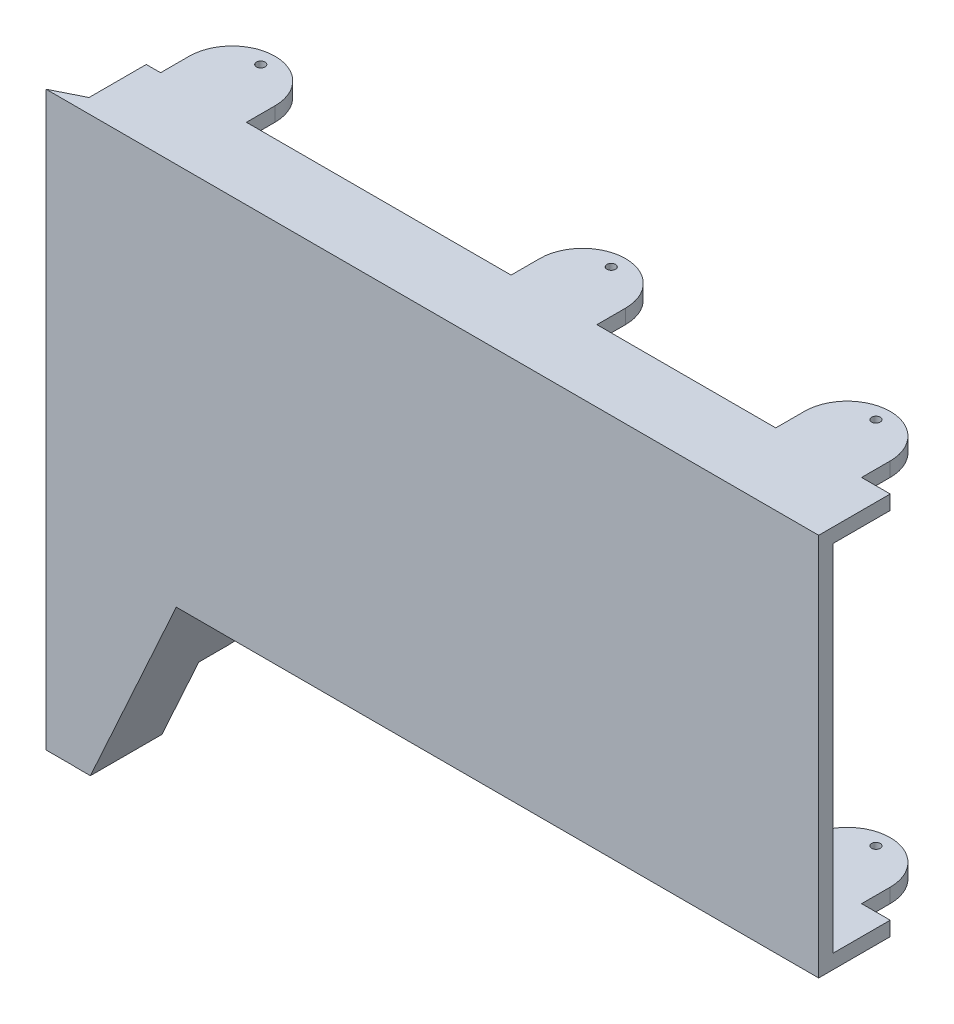
from build123d import *

# Parameters (mm, degrees)
SKETCH1_W                                  = 260
SKETCH1_H                                  = 134
BOSS_EXTRUDE1_DEPTH                        = 5
SKETCH2_W                                  = 260
SKETCH2_H                                  = 5
BOSS_EXTRUDE2_DEPTH                        = 20
SKETCH4_W                                  = 230
SKETCH4_H                                  = 5
BOSS_EXTRUDE3_DEPTH                        = 20
BOSS_EXTRUDE4_DEPTH                        = 5
SKETCH7_R                                  = 1.5
CUT_EXTRUDE1_DEPTH                         = 5
BOSS_EXTRUDE5_DEPTH                        = 5
BOSS_EXTRUDE9_DEPTH                        = 25
BOSS_EXTRUDE10_DEPTH                       = 200
BOSS_EXTRUDE11_DEPTH                       = 5
SKETCH14_R                                 = 1.5
CUT_EXTRUDE2_DEPTH                         = 5
BOSS_EXTRUDE12_DEPTH                       = 10
BOSS_EXTRUDE13_DEPTH                       = 5
SKETCH19_R                                 = 1.5
CUT_EXTRUDE4_DEPTH                         = 307.022874962
CUT_EXTRUDE4_DEPTH_BACK                    = 307.022874962
MIRROR4_AT_THE_SECOND_PLANE_COPY_1_DEPTH   = 5
MIRROR4_AT_THE_SECOND_PLANE_COPY_2_SKETC_R = 1.5
MIRROR4_AT_THE_SECOND_PLANE_COPY_2_DEPTH   = 5


with BuildPart() as part:
    # Sketch1 → Boss-Extrude1 (new body)
    with BuildSketch(Plane.XY):
        with Locations((130, -67)):
            Rectangle(SKETCH1_W, SKETCH1_H)
    extrude(amount=BOSS_EXTRUDE1_DEPTH)

    # Sketch2 → Boss-Extrude2 (add)
    with BuildSketch(Plane(origin=(0, 0, 0), x_dir=(-1, 0, 0), z_dir=(0, 0, -1))):
        with Locations((-130, -2.5)):
            Rectangle(SKETCH2_W, SKETCH2_H)
    extrude(amount=BOSS_EXTRUDE2_DEPTH)

    # Sketch4 → Boss-Extrude3 (add)
    with BuildSketch(Plane(origin=(0, 0, 0), x_dir=(-1, 0, 0), z_dir=(0, 0, -1))):
        with Locations((-145, -131.5)):
            Rectangle(SKETCH4_W, SKETCH4_H)
    extrude(amount=BOSS_EXTRUDE3_DEPTH)

    # Sketch6 → Boss-Extrude4 (add)
    with BuildSketch(Plane(origin=(0, 0, 0), x_dir=(1, 0, 0), z_dir=(0, 1, 0))):
        with BuildLine():
            Line((5, 20), (5, 30))
            ThreePointArc((5, 30), (20, 45), (35, 30))
            Line((35, 30), (35, 20))
            Line((35, 20), (5, 20))
        make_face()
    extrude(amount=-BOSS_EXTRUDE4_DEPTH)

    # Sketch7 → Cut-Extrude1 (cut)
    with BuildSketch(Plane(origin=(0, 0, 0), x_dir=(1, 0, 0), z_dir=(0, 1, 0))):
        with Locations(Location((20, 40, 0), (0, 0, 270))):
            Circle(SKETCH7_R)
    extrude(amount=-CUT_EXTRUDE1_DEPTH, mode=Mode.SUBTRACT)

    # Sketch8 → Boss-Extrude5 (add)
    with BuildSketch(Plane(origin=(0, 0, 0), x_dir=(-1, 0, 0), z_dir=(0, 0, -1))):
        Polygon((-30, -134), (0, -200), (0, -134), align=None)
    extrude(amount=-BOSS_EXTRUDE5_DEPTH)

    # Sketch10 → Boss-Extrude9 (add)
    with BuildSketch(Plane.XY.offset(5)):
        Polygon((30, -134), (35.492293624, -134), (5.469823482, -200.049434314), (-0.022470143, -200.049434314), align=None)
    extrude(amount=-BOSS_EXTRUDE9_DEPTH)

    # Sketch11 → Boss-Extrude10 (add)
    with BuildSketch(Plane(origin=(0, 0, 0), x_dir=(1, 0, 0), z_dir=(0, 1, 0))):
        Polygon((0, 0), (-10, -5), (0, -5), align=None)
    extrude(amount=-BOSS_EXTRUDE10_DEPTH)

    # Sketch13 → Boss-Extrude11 (add)
    with BuildSketch(Plane(origin=(0, 0, 0), x_dir=(1, 0, 0), z_dir=(0, 1, 0))):
        with BuildLine():
            Line((220, 30), (220, 20))
            Line((220, 20), (250, 20))
            Line((250, 20), (250, 29.999997567))
            ThreePointArc((250, 29.999997567), (235.000001217, 44.999997567), (220, 30))
        make_face()
    boss_extrude11 = extrude(amount=-BOSS_EXTRUDE11_DEPTH)

    # Sketch14 → Cut-Extrude2 (cut)
    with BuildSketch(Plane(origin=(0, 0, 0), x_dir=(1, 0, 0), z_dir=(0, 1, 0))):
        with Locations(Location((235, 39.999997567, 0), (0, 0, 270))):
            Circle(SKETCH14_R)
    cut_extrude2 = extrude(amount=-CUT_EXTRUDE2_DEPTH, mode=Mode.SUBTRACT)

    # Sketch15 → Boss-Extrude12 (add)
    with BuildSketch(Plane(origin=(0, 0, -20), x_dir=(-1, 0, 0), z_dir=(0, 0, -1))):
        Polygon((-30.758876552, -144.41351756), (-26.207044165, -142.344502838), (-13.792955835, -169.655497162), (-18.344788223, -171.724511883), align=None)
    extrude(amount=BOSS_EXTRUDE12_DEPTH)

    # Sketch17 → Boss-Extrude13 (add)
    with BuildSketch(Plane(origin=(75.342465753, -34.246575342, 0), x_dir=(0, 0, 1), z_dir=(-0.9103664774626048, 0.41380294430118403, 0))):
        with BuildLine():
            Line((-30, -118.741111598), (-30, -148.741111598))
            ThreePointArc((-30, -148.741111598), (-45, -133.741111598), (-30, -118.741111598))
        make_face()
    extrude(amount=-BOSS_EXTRUDE13_DEPTH)

    # Sketch19 → Cut-Extrude4 (cut, two sides)
    with BuildSketch(Plane(origin=(0, -155, 0), x_dir=(1, 0, 0), z_dir=(0, 1, 0))) as cut_extrude4_sk:
        with Locations(Location((20, 40, 0), (0, 0, 270))):
            Circle(SKETCH19_R)
    extrude(amount=CUT_EXTRUDE4_DEPTH, mode=Mode.SUBTRACT)
    extrude(cut_extrude4_sk.sketch, amount=-CUT_EXTRUDE4_DEPTH_BACK, mode=Mode.SUBTRACT)

    # Mirror4: Boss-Extrude11, Cut-Extrude2 across plane
    add(boss_extrude11.mirror(Plane.ZX.offset(-67)))
    add(cut_extrude2.mirror(Plane.ZX.offset(-67)), mode=Mode.SUBTRACT)

    # Mirror4 at the second plane: Boss-Extrude11, Cut-Extrude2 across plane
    add(boss_extrude11.mirror(Plane.ZY.offset(-188.75)))
    add(cut_extrude2.mirror(Plane.ZY.offset(-188.75)), mode=Mode.SUBTRACT)

    # Mirror4 at the second plane copy 1 sketc → Mirror4 at the second plane copy 1 (add)
    with BuildSketch(Plane(origin=(377.5, -134, 0), x_dir=(-1, 0, 0), z_dir=(0, -1, 0))):
        with BuildLine():
            Line((220, 30), (220, 20))
            Line((220, 20), (250, 20))
            Line((250, 20), (250, 29.999997567))
            ThreePointArc((250, 29.999997567), (235.000001217, 44.999997567), (220, 30))
        make_face()
    extrude(amount=-MIRROR4_AT_THE_SECOND_PLANE_COPY_1_DEPTH)

    # Mirror4 at the second plane copy 2 sketc → Mirror4 at the second plane copy 2 (cut)
    with BuildSketch(Plane(origin=(377.5, -134, 0), x_dir=(-1, 0, 0), z_dir=(0, -1, 0))):
        with Locations(Location((235, 39.999997567, 0), (0, 0, 270))):
            Circle(MIRROR4_AT_THE_SECOND_PLANE_COPY_2_SKETC_R)
    extrude(amount=-MIRROR4_AT_THE_SECOND_PLANE_COPY_2_DEPTH, mode=Mode.SUBTRACT)


solid = part.part
